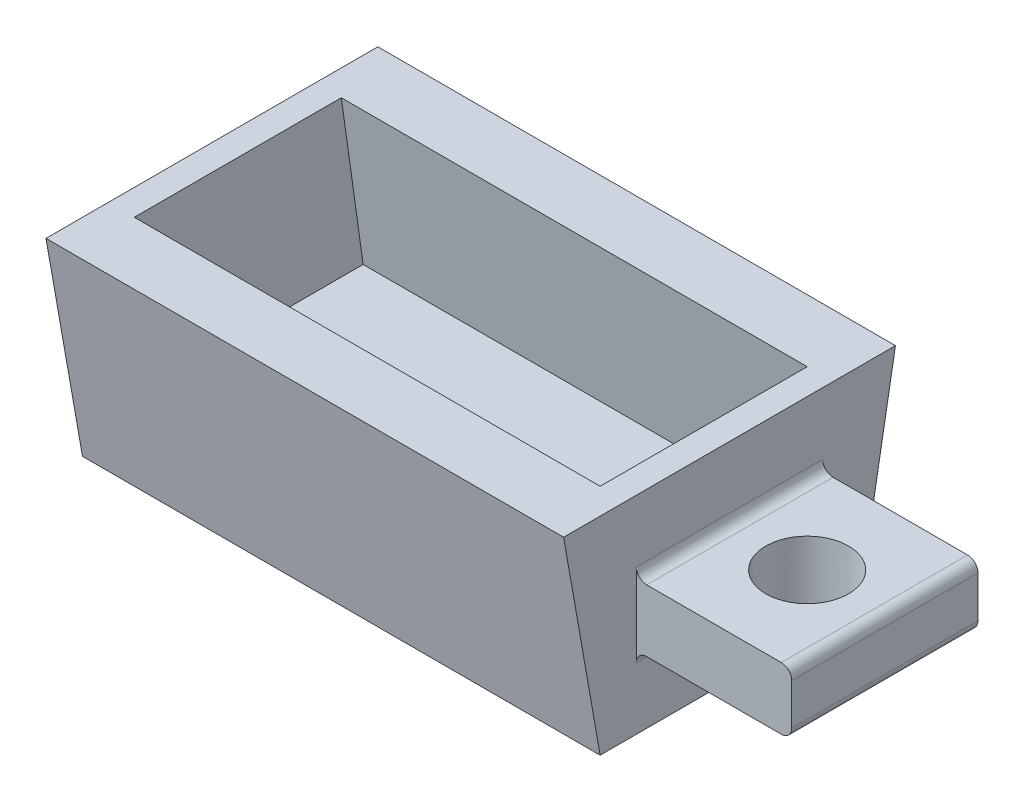
from build123d import *

# Parameters (mm, degrees)
SKETCH1_W           = 100
SKETCH1_H           = 50
BOSS_EXTRUDE1_DEPTH = 40
SKETCH2_W           = 90
SKETCH2_H           = 40
CUT_EXTRUDE1_DEPTH  = 30
SKETCH3_W           = 36
SKETCH3_H           = 12
BOSS_EXTRUDE2_DEPTH = 30
FILLET1_R           = 2
DRAFT2_ANGLE        = 10
DRAFT5_ANGLE        = -8
SKETCH4_R           = 8
CUT_EXTRUDE2_DEPTH  = 27
CUT_EXTRUDE2_TAPER  = 3


with BuildPart() as part:
    # Sketch1 → Boss-Extrude1 (new body)
    with BuildSketch(Plane(origin=(0, 0, 0), x_dir=(1, 0, 0), z_dir=(0, 1, 0))):
        Rectangle(SKETCH1_W, SKETCH1_H)
    extrude(amount=BOSS_EXTRUDE1_DEPTH)

    # Sketch2 → Cut-Extrude1 (cut)
    with BuildSketch(Plane(origin=(0, 40, 0), x_dir=(1, 0, 0), z_dir=(0, 1, 0))):
        Rectangle(SKETCH2_W, SKETCH2_H)
    extrude(amount=-CUT_EXTRUDE1_DEPTH, mode=Mode.SUBTRACT)

    # Sketch3 → Boss-Extrude2 (add)
    with BuildSketch(Plane(origin=(50, 0, 0), x_dir=(0, 0, -1), z_dir=(1, 0, 0))):
        with Locations((0, 20)):
            Rectangle(SKETCH3_W, SKETCH3_H)
    extrude(amount=BOSS_EXTRUDE2_DEPTH)

    # Fillet1
    fillet1_edges = [part.edges().sort_by_distance(p)[0] for p in [
        (50, 26, 0),
        (50, 14, 0),
        (80, 26, 0),
        (80, 14, 0),
    ]]
    fillet(fillet1_edges, radius=FILLET1_R)

    # Draft2
    draft2_faces = [part.faces().sort_by_distance(p)[0] for p in [
        (0, 20, -25),
        (0, 20, 25),
    ]]
    draft(draft2_faces, Plane(origin=(0, 0, 0), x_dir=(0, 0, -1), z_dir=(0, -1, 0)), DRAFT2_ANGLE)

    # Draft5
    draft5_faces = [part.faces().sort_by_distance(p)[0] for p in [
        (0, 25, 20),
        (0, 25, -20),
    ]]
    draft(draft5_faces, Plane.ZX.offset(40), DRAFT5_ANGLE)

    # Sketch4 → Cut-Extrude2 (cut, through all)
    with BuildSketch(Plane(origin=(0, 26, 0), x_dir=(1, 0, 0), z_dir=(0, 1, 0))):
        with Locations((65, 0)):
            Circle(SKETCH4_R)
    extrude(amount=-CUT_EXTRUDE2_DEPTH, taper=CUT_EXTRUDE2_TAPER, mode=Mode.SUBTRACT)


solid = part.part
